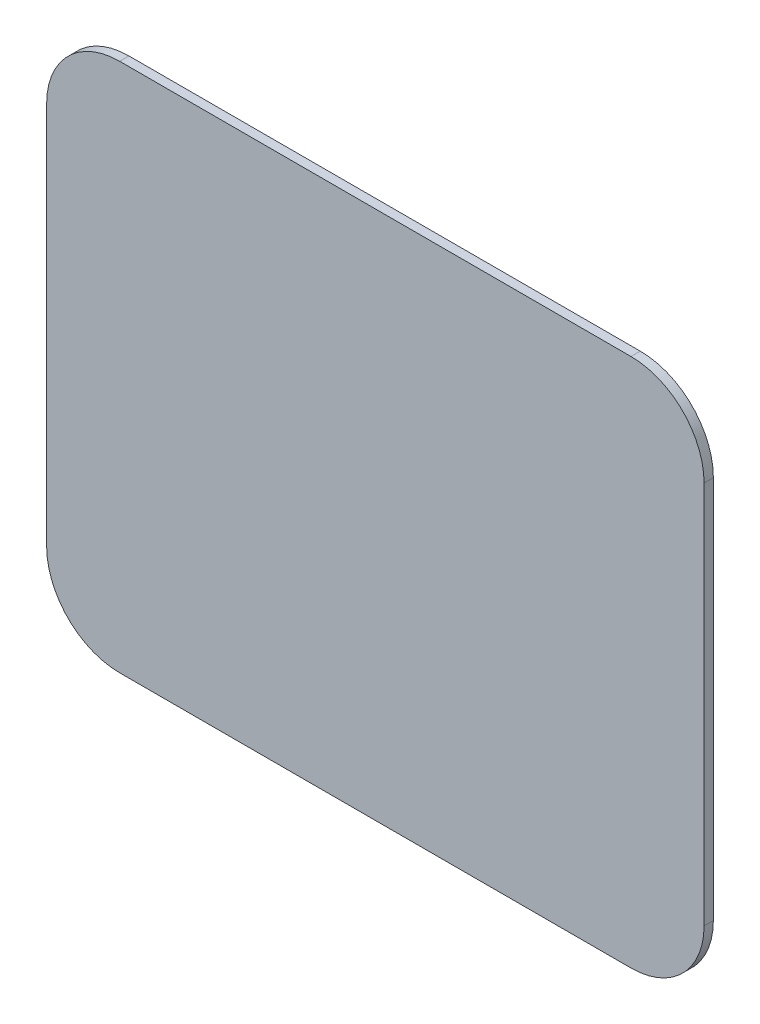
from build123d import *

# Parameters (mm, degrees)
SKETCH1_W           = 36
SKETCH1_H           = 29
BOSS_EXTRUDE1_DEPTH = 0.508
FILLET1_R           = 4


with BuildPart() as part:
    # Sketch1 → Boss-Extrude1 (new body)
    with BuildSketch(Plane.XY):
        Rectangle(SKETCH1_W, SKETCH1_H)
    extrude(amount=BOSS_EXTRUDE1_DEPTH)

    # Fillet1
    fillet1_edges = [part.edges().sort_by_distance(p)[0] for p in [
        (-18, 14.5, 0.254),
        (18, 14.5, 0.254),
        (18, -14.5, 0.254),
        (-18, -14.5, 0.254),
    ]]
    fillet(fillet1_edges, radius=FILLET1_R)


solid = part.part
